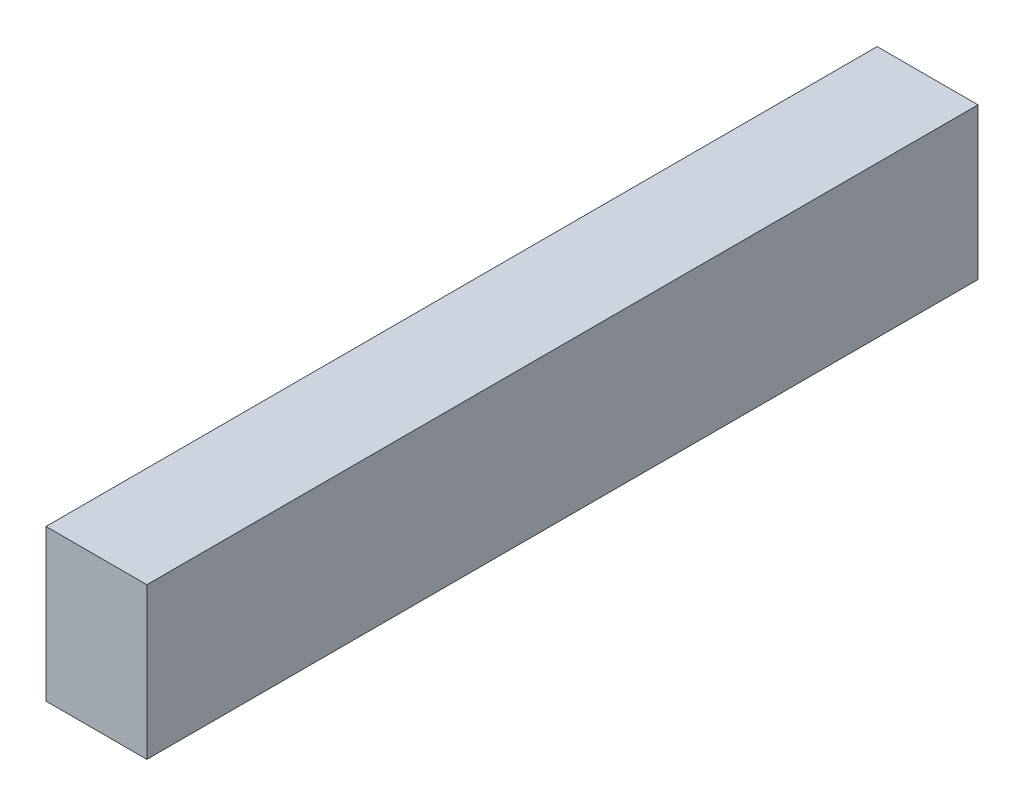
from build123d import *

# Parameters (mm, degrees)
SKETCH1_W           = 3.175
SKETCH1_H           = 4.7625
BOSS_EXTRUDE1_DEPTH = 26.162


with BuildPart() as part:
    # Sketch1 → Boss-Extrude1 (new body)
    with BuildSketch(Plane.XY):
        Rectangle(SKETCH1_W, SKETCH1_H)
    extrude(amount=BOSS_EXTRUDE1_DEPTH)


solid = part.part
